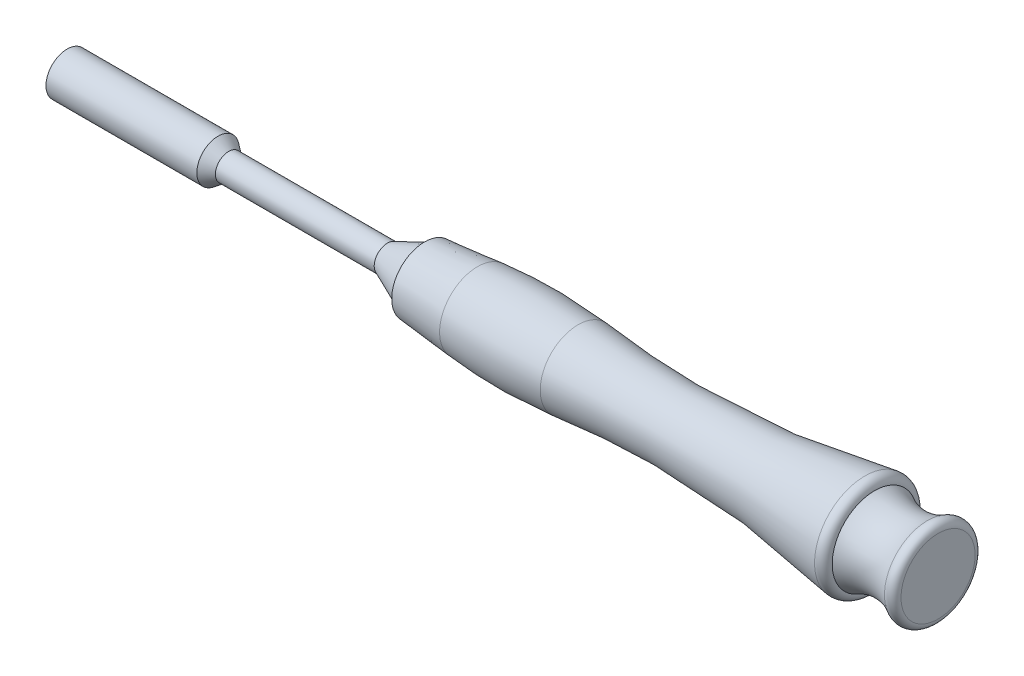
from build123d import *

# Parameters (mm, degrees)
HEXAGONALHEAD_DEPTH       = 5.25
SKETCH3_R                 = 2.5
CIRCULARCENTRALHOLE_DEPTH = 24


with BuildPart() as part:
    # Sketch1 → AluminiumPart (revolve)
    with BuildSketch(Plane.XY):
        Polygon((0, 4), (28.5, 4), (30.5, 2.5), (60.5, 2.5), (60.5, 0), (0, 0), align=None)
    revolve(axis=Axis((184.722030444, 0, 0), (-1, 0, 0)))

    # Sketch2 → HexagonalHead (cut)
    with BuildSketch(Plane.ZY):
        Polygon((-2.8, 1.616580754), (0, 3.233161507), (2.8, 1.616580754), (2.8, -1.616580754), (0, -3.233161507), (-2.8, -1.616580754), align=None)
    extrude(amount=-HEXAGONALHEAD_DEPTH, mode=Mode.SUBTRACT)

    # Sketch3 → CircularCentralHole (cut)
    with BuildSketch(Plane.ZY):
        Circle(SKETCH3_R)
    extrude(amount=-CIRCULARCENTRALHOLE_DEPTH, mode=Mode.SUBTRACT)

    # Sketch4 → FirstGreenPart (revolve)
    with BuildSketch(Plane.XY):
        Polygon((60.5, 0), (60.5, 2.5), (67.5, 5.5), (67.5, 0), align=None)
    revolve(axis=Axis((184.722030444, 0, 0), (-1, 0, 0)))

    # Sketch5 → FirstBlackPart (revolve)
    with BuildSketch(Plane.XY):
        with BuildLine():
            Line((67.5, 6.195683888), (77.5, 7.15))
            ThreePointArc((77.5, 7.15), (87, 7.602272753), (96.5, 7.15))
            Line((96.5, 7.15), (96.5, 0))
            Line((96.5, 0), (67.5, 0))
            Line((67.5, 0), (67.5, 6.195683888))
        make_face()
    revolve(axis=Axis((184.722030444, 0, 0), (-1, 0, 0)))

    # Sketch6 → SecondGreenPart (revolve)
    with BuildSketch(Plane.XY):
        with BuildLine():
            Line((152.5, 8), (152.5, 0))
            Line((152.5, 0), (96.5, 0))
            Line((96.5, 0), (96.5, 7.15))
            ThreePointArc((96.5, 7.15), (123.675746685, 6.231641521), (150.66986499, 9.5))
            ThreePointArc((150.66986499, 9.5), (151.939948886, 9.183151951), (152.5, 8))
        make_face()
    revolve(axis=Axis((184.722030444, 0, 0), (-1, 0, 0)))

    # Sketch7 → LastBlackPart (revolve)
    with BuildSketch(Plane.XY):
        with BuildLine():
            Line((152.5, 0), (152.5, 8))
            ThreePointArc((152.5, 8), (157.517257353, 6.700790451), (162.5, 8.126655981))
            ThreePointArc((162.5, 8.126655981), (163.829223328, 8.147753643), (164.5, 7))
            Line((164.5, 7), (164.5, 0))
            Line((164.5, 0), (152.5, 0))
        make_face()
    revolve(axis=Axis((184.722030444, 0, 0), (-1, 0, 0)))


solid = part.part
